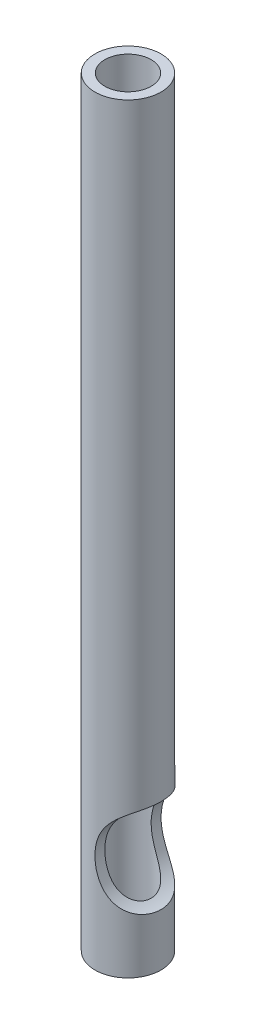
from build123d import *

# Parameters (mm, degrees)
SKETCH_2_R          = 1.5
CUT_EXTRUDE_1_DEPTH = 5


with BuildPart() as part:
    # Эскиз1 → Повернуть1 (revolve)
    with BuildSketch(Plane(origin=(0, 0, 0), x_dir=(0, 0, -1), z_dir=(1, 0, 0))):
        Polygon((0.7, 13), (0, 13), (0, 7), (0.7, 7), (0.7, 0), (1, 0), (1, 23), (0.7, 23), align=None)
    revolve(axis=Axis((0, 0, 0), (0, 1, 0)))

    # Эскиз2 → Вырез-Вытянуть1 (cut, symmetric)
    with BuildSketch(Plane.XY):
        with Locations((1.5, 3)):
            Circle(SKETCH_2_R)
    extrude(amount=CUT_EXTRUDE_1_DEPTH, both=True, mode=Mode.SUBTRACT)


solid = part.part
